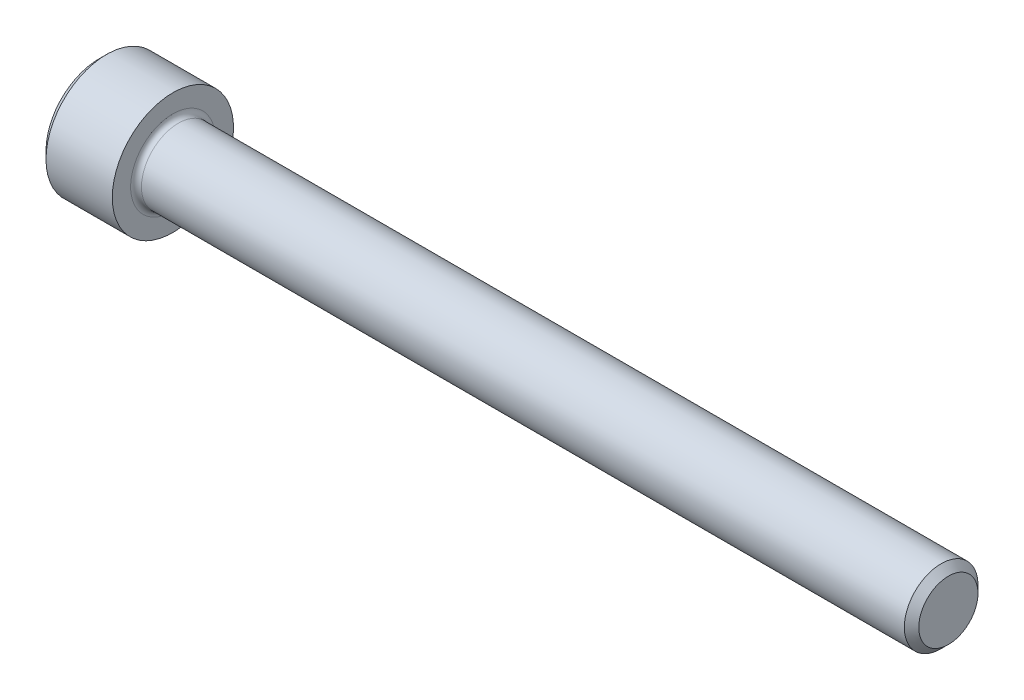
from build123d import *

# Parameters (mm, degrees)
FILLET1_R   = 0.3556
HEX_2_DEPTH = 2.286


with BuildPart() as part:
    # BodySke → Base-Revolve (revolve)
    with BuildSketch(Plane.XY):
        Polygon((0, 0), (0, 3.48615), (0.4826, 3.96875), (4.826, 3.96875), (4.826, 2.413), (55.15356, 2.413), (55.626, 1.94056), (55.626, 0), align=None)
    revolve(axis=Axis((-31.75, 0, 0), (1, 0, 0)))

    # Fillet1
    fillet1_edges = [part.edges().sort_by_distance(p)[0] for p in [
        (4.826, -2.413, 0),
    ]]
    fillet(fillet1_edges, radius=FILLET1_R)

    # Sketch2 → Hex-PreBroach (revolve, cut)
    with BuildSketch(Plane.XY):
        Polygon((0, 1.98501), (2.286, 1.98501), (3.432046058, 0), (0, 0), align=None)
    revolve(axis=Axis((0, 0, 0), (1, 0, 0)), mode=Mode.SUBTRACT)

    # Sketch3 → Hex 2 (cut)
    with BuildSketch(Plane(origin=(0, 0, 0), x_dir=(0, 0.5, 0.866025404), z_dir=(-1, 0, 0))):
        Polygon((1.146046058, 1.98501), (-1.146046058, 1.98501), (-2.292092116, 0), (-1.146046058, -1.98501), (1.146046058, -1.98501), (2.292092116, 0), align=None)
    extrude(amount=-HEX_2_DEPTH, mode=Mode.SUBTRACT)


solid = part.part
